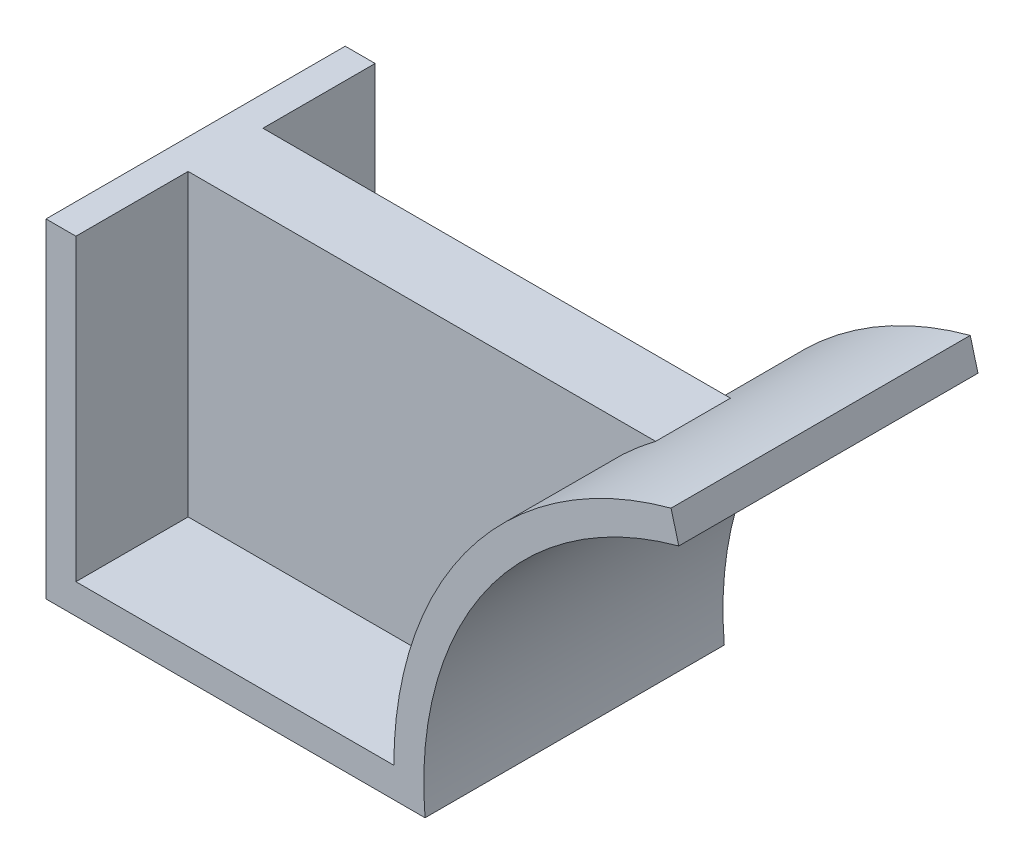
from build123d import *

# Parameters (mm, degrees)
EXTRUDE_THIN1_DEPTH = 80
BOSS_EXTRUDE1_REACH = 163.189
SKETCH2_W           = 20
SKETCH2_H           = 80


with BuildPart() as part:
    # Sketch1 → Extrude-Thin1 (new body)
    with BuildSketch(Plane.XY):
        with BuildLine():
            Line((0, 80), (0, 0))
            Line((0, 0), (85, 0))
            ThreePointArc((85, 0), (105.664665971, 60.876142901), (159.11809549, 96.592582629))
            Line((159.11809549, 96.592582629), (161.188647851, 88.865176019))
            ThreePointArc((161.188647851, 88.865176019), (109.643288684, 52.776567335), (93.348486101, -8))
            Line((93.348486101, -8), (-8, -8))
            Line((-8, -8), (-8, 80))
            Line((-8, 80), (0, 80))
        make_face()
    extrude(amount=EXTRUDE_THIN1_DEPTH)

    # Sketch2 → Boss-Extrude1 (add, up to next)
    with BuildSketch(Plane(origin=(0, 0, 0), x_dir=(0, 0, -1), z_dir=(1, 0, 0)), mode=Mode.PRIVATE) as boss_extrude1_sk1:
        with Locations((-40, 40)):
            Rectangle(SKETCH2_W, SKETCH2_H)
    boss_extrude1_tool1 = extrude(boss_extrude1_sk1.sketch, amount=BOSS_EXTRUDE1_REACH, mode=Mode.PRIVATE) - part.part
    add(boss_extrude1_tool1.solids().sort_by_distance((0, 40, 40))[0])


solid = part.part
